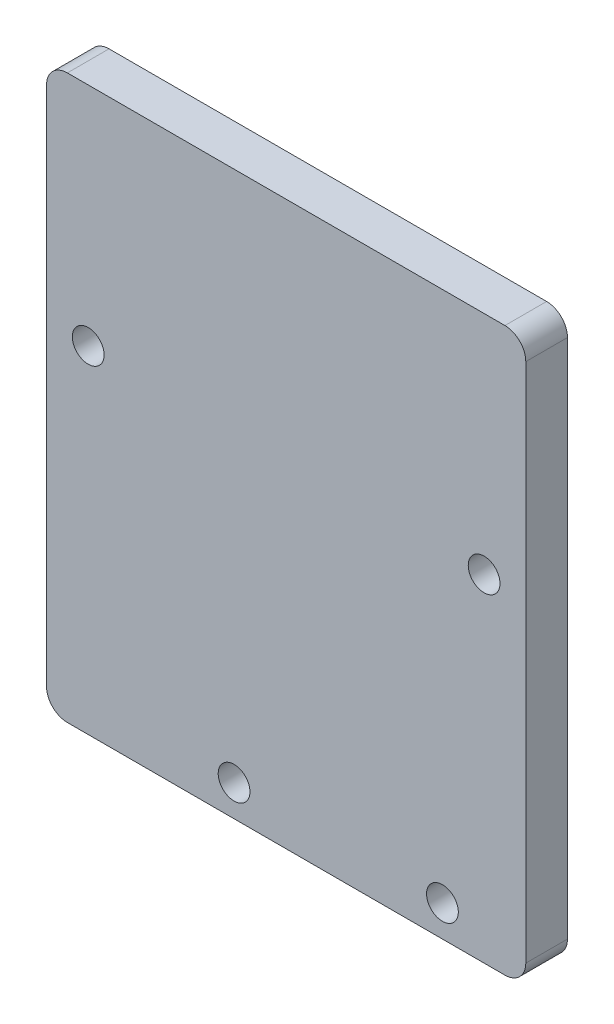
from build123d import *

# Parameters (mm, degrees)
SKETCH_1_W          = 46
SKETCH_1_H          = 54
EXTRUDE_1_DEPTH     = 4
SKETCH_5_R          = 1.525
CUT_EXTRUDE_1_DEPTH = 54
FILLET_1_R          = 2


with BuildPart() as part:
    # 草图1 → 凸台-拉伸1 (new body)
    with BuildSketch(Plane.XY):
        Rectangle(SKETCH_1_W, SKETCH_1_H)
    extrude(amount=EXTRUDE_1_DEPTH)

    # 草图5 → 切除-拉伸1 (cut)
    with BuildSketch(Plane(origin=(0, 0, 0), x_dir=(-1, 0, 0), z_dir=(0, 0, -1))):
        with Locations((5, -24)):
            Circle(SKETCH_5_R)
        with Locations((-15, -24)):
            Circle(SKETCH_5_R)
        with Locations((-19, 5.310310448)):
            Circle(SKETCH_5_R)
        with Locations((19, 5.310310448)):
            Circle(SKETCH_5_R)
    extrude(amount=-CUT_EXTRUDE_1_DEPTH, mode=Mode.SUBTRACT)

    # 圆角1
    fillet_1_edges = [part.edges().sort_by_distance(p)[0] for p in [
        (23, -27, 2),
        (-23, -27, 2),
        (-23, 27, 2),
        (23, 27, 2),
    ]]
    fillet(fillet_1_edges, radius=FILLET_1_R)


solid = part.part
